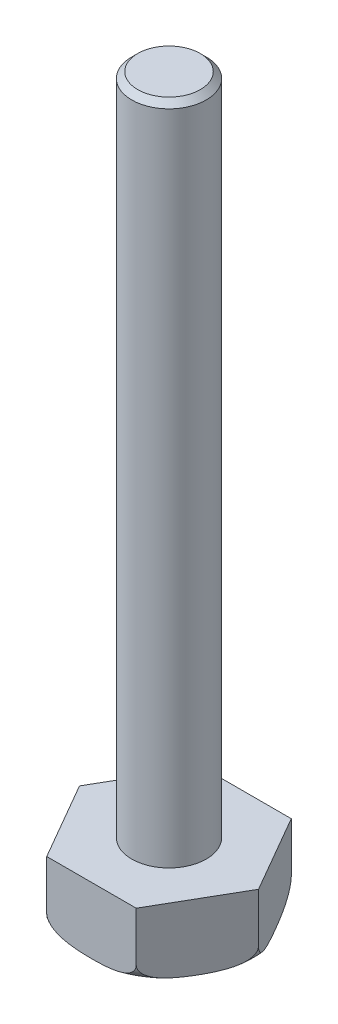
from build123d import *

# Parameters (mm, degrees)
BOSS_EXTRUDE1_DEPTH = 45
SKETCH2_R           = 25
BOSS_EXTRUDE2_DEPTH = 445
CHAMFER1_SIZE       = 4


with BuildPart() as part:
    # Sketch1 → Boss-Extrude1 (new body)
    with BuildSketch(Plane(origin=(0, 0, 0), x_dir=(1, 0, 0), z_dir=(0, 1, 0))):
        Polygon((-60.044427996, 0), (-30.022213998, -52), (30.022213998, -52), (60.044427996, 0), (30.022213998, 52), (-30.022213998, 52), align=None)
    extrude(amount=BOSS_EXTRUDE1_DEPTH)

    # Sketch2 → Boss-Extrude2 (add)
    with BuildSketch(Plane(origin=(0, 45, 0), x_dir=(1, 0, 0), z_dir=(0, 1, 0))):
        Circle(SKETCH2_R)
    extrude(amount=BOSS_EXTRUDE2_DEPTH)

    # Sketch3 → Cut-Revolve1 (revolve, cut)
    with BuildSketch(Plane.XY):
        with BuildLine():
            Line((48.044427996, 0), (60.044427996, 0))
            Line((60.044427996, 0), (60.044427996, 12))
            ThreePointArc((60.044427996, 12), (56.52970937, 3.514718626), (48.044427996, 0))
        make_face()
    revolve(axis=Axis((0, 490, 0), (0, -1, 0)), mode=Mode.SUBTRACT)

    # Chamfer1
    chamfer1_edges = [part.edges().sort_by_distance(p)[0] for p in [
        (-25, 490, 0),
    ]]
    chamfer(chamfer1_edges, length=CHAMFER1_SIZE)


solid = part.part
